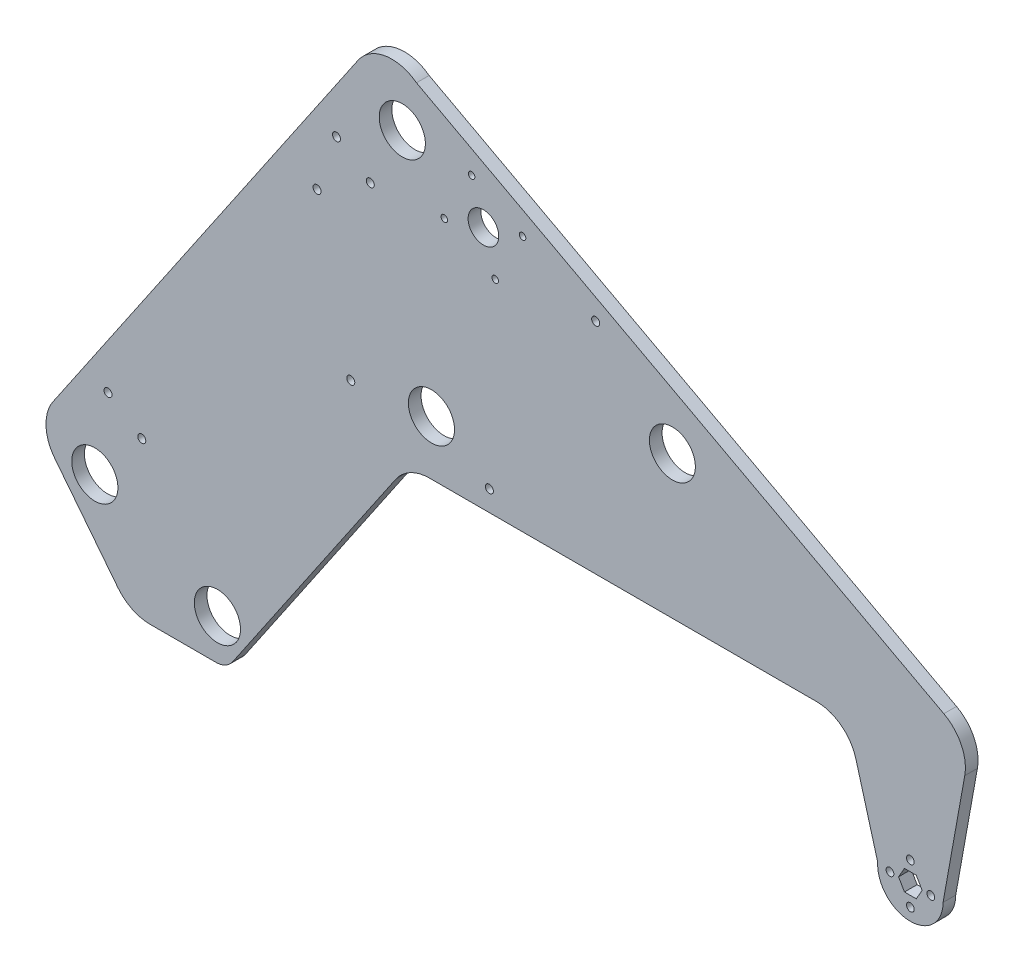
from build123d import *

# Parameters (mm, degrees)
MODEL_R             = 14.351
MODEL_R_2           = 2.413
MODEL_R_3           = 14.2875
BOSS_EXTRUDE1_DEPTH = 7.874
CUT_EXTRUDE3_REACH  = 9.874
SKETCH29_R          = 2.032
SKETCH29_R_2        = 9.525
CUT_EXTRUDE4_REACH  = 9.874
SKETCH34_R          = 2.4892
CUT_EXTRUDE5_REACH  = 9.874
SKETCH40_R          = 2.4892


with BuildPart() as part:
    # Model → Boss-Extrude1 (new body)
    with BuildSketch(Plane.XY):
        with BuildLine():
            Line((-44.522451968, 230.070582963), (-200.005250584, 313.419470721))
            ThreePointArc((-200.005250584, 313.419470721), (-219.438743814, 318.210854709), (-236.308771814, 307.439588539))
            Line((-236.308771814, 307.439588539), (-425.925316767, 28.829603592))
            ThreePointArc((-425.925316767, 28.829603592), (-430.312243104, 13.671313347), (-424.900993017, -1.152223962))
            Line((-424.900993017, -1.152223962), (-385.581467186, -51.204797614))
            ThreePointArc((-385.581467186, -51.204797614), (-376.711879358, -58.358090396), (-365.607528193, -60.913979882))
            Line((-365.607528193, -60.913979882), (-324.737451002, -60.913979882))
            ThreePointArc((-324.737451002, -60.913979882), (-318.798508014, -59.439796386), (-314.23831963, -55.359484793))
            Line((-314.23831963, -55.359484793), (-212.899365952, 93.541257838))
            ThreePointArc((-212.899365952, 93.541257838), (-203.778989185, 101.701881024), (-191.901103209, 104.650248016))
            Line((-191.901103209, 104.650248016), (48.661197018, 104.650248016))
            ThreePointArc((48.661197018, 104.650248016), (64.032332507, 99.471232012), (73.135172194, 86.046168785))
            Line((73.135172194, 86.046168785), (86.727013732, 37.098218434))
            ThreePointArc((86.727013732, 37.098218434), (106.362581421, 15.501750179), (127.326236921, 35.811553418))
            Line((127.326236921, 35.811553418), (140.807890588, 110.809453484))
            ThreePointArc((140.807890588, 110.809453484), (138.675228362, 126.361225539), (127.809114586, 137.689660276))
            Line((127.809114586, 137.689660276), (-44.522451968, 230.070582963))
        make_face()
        with Locations((-323.775189267, -35.513979882)):
            Circle(MODEL_R, mode=Mode.SUBTRACT)
        with Locations((-399.975189267, 2.586020118)):
            Circle(MODEL_R, mode=Mode.SUBTRACT)
        with Locations((107.006236921, 23.111553418)):
            Circle(MODEL_R_2, mode=Mode.SUBTRACT)
        with Locations((94.306236921, 35.811553418)):
            Circle(MODEL_R_2, mode=Mode.SUBTRACT)
        Polygon((110.67241113, 42.161553418), (114.33858534, 35.811553418), (110.67241113, 29.461553418), (103.340062712, 29.461553418), (99.673888502, 35.811553418), (103.340062712, 42.161553418), (107.006236921, 42.161553418), align=None, mode=Mode.SUBTRACT)
        with Locations((119.706236921, 35.811553418)):
            Circle(MODEL_R_2, mode=Mode.SUBTRACT)
        with Locations((107.006236921, 48.511553418)):
            Circle(MODEL_R_2, mode=Mode.SUBTRACT)
        with Locations((-190.707148919, 138.516914683)):
            Circle(MODEL_R, mode=Mode.SUBTRACT)
        with Locations((-208.832932893, 283.437784316)):
            Circle(MODEL_R, mode=Mode.SUBTRACT)
        with Locations((-40.935516122, 193.433854171)):
            Circle(MODEL_R_3, mode=Mode.SUBTRACT)
    extrude(amount=BOSS_EXTRUDE1_DEPTH)

    # Sketch29 → Cut-Extrude3 (cut, up to next)
    with BuildSketch(Plane.XY.offset(7.874), mode=Mode.PRIVATE) as cut_extrude3_sk1:
        with Locations((-182.711721066, 249.056735353)):
            Circle(SKETCH29_R)
    cut_extrude3_tool1 = extrude(cut_extrude3_sk1.sketch, amount=-CUT_EXTRUDE3_REACH, mode=Mode.PRIVATE) & part.part
    add(cut_extrude3_tool1.solids().sort_by_distance((-182.711721, 249.056735, 7.874))[0], mode=Mode.SUBTRACT)
    # Sketch29 → Cut-Extrude3 (cut, up to next)
    with BuildSketch(Plane.XY.offset(7.874), mode=Mode.PRIVATE) as cut_extrude3_sk2:
        with Locations((-134.081376724, 263.744472048)):
            Circle(SKETCH29_R)
    cut_extrude3_tool2 = extrude(cut_extrude3_sk2.sketch, amount=-CUT_EXTRUDE3_REACH, mode=Mode.PRIVATE) & part.part
    add(cut_extrude3_tool2.solids().sort_by_distance((-134.081377, 263.744472, 7.874))[0], mode=Mode.SUBTRACT)
    # Sketch29 → Cut-Extrude3 (cut, up to next)
    with BuildSketch(Plane.XY.offset(7.874), mode=Mode.PRIVATE) as cut_extrude3_sk3:
        with Locations((-165.740417242, 280.715775871)):
            Circle(SKETCH29_R)
    cut_extrude3_tool3 = extrude(cut_extrude3_sk3.sketch, amount=-CUT_EXTRUDE3_REACH, mode=Mode.PRIVATE) & part.part
    add(cut_extrude3_tool3.solids().sort_by_distance((-165.740417, 280.715776, 7.874))[0], mode=Mode.SUBTRACT)
    # Sketch29 → Cut-Extrude3 (cut, up to next)
    with BuildSketch(Plane.XY.offset(7.874), mode=Mode.PRIVATE) as cut_extrude3_sk4:
        with Locations((-151.052680548, 232.08543153)):
            Circle(SKETCH29_R)
    cut_extrude3_tool4 = extrude(cut_extrude3_sk4.sketch, amount=-CUT_EXTRUDE3_REACH, mode=Mode.PRIVATE) & part.part
    add(cut_extrude3_tool4.solids().sort_by_distance((-151.052681, 232.085432, 7.874))[0], mode=Mode.SUBTRACT)
    # Sketch29 → Cut-Extrude3 (cut, up to next)
    with BuildSketch(Plane.XY.offset(7.874), mode=Mode.PRIVATE) as cut_extrude3_sk5:
        with Locations((-158.396548895, 256.400603701)):
            Circle(SKETCH29_R_2)
    cut_extrude3_tool5 = extrude(cut_extrude3_sk5.sketch, amount=-CUT_EXTRUDE3_REACH, mode=Mode.PRIVATE) & part.part
    add(cut_extrude3_tool5.solids().sort_by_distance((-158.396549, 256.400604, 7.874))[0], mode=Mode.SUBTRACT)

    # Sketch34 → Cut-Extrude4 (cut, up to next)
    with BuildSketch(Plane.XY.offset(7.874), mode=Mode.PRIVATE) as cut_extrude4_sk1:
        with Locations((-228.733222311, 245.210842485)):
            Circle(SKETCH34_R)
    cut_extrude4_tool1 = extrude(cut_extrude4_sk1.sketch, amount=-CUT_EXTRUDE4_REACH, mode=Mode.PRIVATE) & part.part
    add(cut_extrude4_tool1.solids().sort_by_distance((-228.733222, 245.210842, 7.874))[0], mode=Mode.SUBTRACT)
    # Sketch34 → Cut-Extrude4 (cut, up to next)
    with BuildSketch(Plane.XY.offset(7.874), mode=Mode.PRIVATE) as cut_extrude4_sk2:
        with Locations((-249.731485055, 259.501852308)):
            Circle(SKETCH34_R)
    cut_extrude4_tool2 = extrude(cut_extrude4_sk2.sketch, amount=-CUT_EXTRUDE4_REACH, mode=Mode.PRIVATE) & part.part
    add(cut_extrude4_tool2.solids().sort_by_distance((-249.731485, 259.501852, 7.874))[0], mode=Mode.SUBTRACT)
    # Sketch34 → Cut-Extrude4 (cut, up to next)
    with BuildSketch(Plane.XY.offset(7.874), mode=Mode.PRIVATE) as cut_extrude4_sk3:
        with Locations((-391.784122689, 50.779120634)):
            Circle(SKETCH34_R)
    cut_extrude4_tool3 = extrude(cut_extrude4_sk3.sketch, amount=-CUT_EXTRUDE4_REACH, mode=Mode.PRIVATE) & part.part
    add(cut_extrude4_tool3.solids().sort_by_distance((-391.784123, 50.779121, 7.874))[0], mode=Mode.SUBTRACT)
    # Sketch34 → Cut-Extrude4 (cut, up to next)
    with BuildSketch(Plane.XY.offset(7.874), mode=Mode.PRIVATE) as cut_extrude4_sk4:
        with Locations((-370.785859945, 36.488110812)):
            Circle(SKETCH34_R)
    cut_extrude4_tool4 = extrude(cut_extrude4_sk4.sketch, amount=-CUT_EXTRUDE4_REACH, mode=Mode.PRIVATE) & part.part
    add(cut_extrude4_tool4.solids().sort_by_distance((-370.78586, 36.488111, 7.874))[0], mode=Mode.SUBTRACT)

    # Sketch40 → Cut-Extrude5 (cut, up to next)
    with BuildSketch(Plane(origin=(0, 0, 0), x_dir=(-1, 0, 0), z_dir=(0, 0, -1)), mode=Mode.PRIVATE) as cut_extrude5_sk1:
        with Locations((88.612396107, 240.73693678)):
            Circle(SKETCH40_R)
    cut_extrude5_tool1 = extrude(cut_extrude5_sk1.sketch, amount=-CUT_EXTRUDE5_REACH, mode=Mode.PRIVATE) & part.part
    add(cut_extrude5_tool1.solids().sort_by_distance((-88.612396, 240.736937, 0))[0], mode=Mode.SUBTRACT)
    # Sketch40 → Cut-Extrude5 (cut, up to next)
    with BuildSketch(Plane(origin=(0, 0, 0), x_dir=(-1, 0, 0), z_dir=(0, 0, -1)), mode=Mode.PRIVATE) as cut_extrude5_sk2:
        with Locations((154.68970629, 117.473322969)):
            Circle(SKETCH40_R)
    cut_extrude5_tool2 = extrude(cut_extrude5_sk2.sketch, amount=-CUT_EXTRUDE5_REACH, mode=Mode.PRIVATE) & part.part
    add(cut_extrude5_tool2.solids().sort_by_distance((-154.689706, 117.473323, 0))[0], mode=Mode.SUBTRACT)
    # Sketch40 → Cut-Extrude5 (cut, up to next)
    with BuildSketch(Plane(origin=(0, 0, 0), x_dir=(-1, 0, 0), z_dir=(0, 0, -1)), mode=Mode.PRIVATE) as cut_extrude5_sk3:
        with Locations((240.850237606, 132.8680637)):
            Circle(SKETCH40_R)
    cut_extrude5_tool3 = extrude(cut_extrude5_sk3.sketch, amount=-CUT_EXTRUDE5_REACH, mode=Mode.PRIVATE) & part.part
    add(cut_extrude5_tool3.solids().sort_by_distance((-240.850238, 132.868064, 0))[0], mode=Mode.SUBTRACT)
    # Sketch40 → Cut-Extrude5 (cut, up to next)
    with BuildSketch(Plane(origin=(0, 0, 0), x_dir=(-1, 0, 0), z_dir=(0, 0, -1)), mode=Mode.PRIVATE) as cut_extrude5_sk4:
        with Locations((261.829815531, 225.169665851)):
            Circle(SKETCH40_R)
    cut_extrude5_tool4 = extrude(cut_extrude5_sk4.sketch, amount=-CUT_EXTRUDE5_REACH, mode=Mode.PRIVATE) & part.part
    add(cut_extrude5_tool4.solids().sort_by_distance((-261.829816, 225.169666, 0))[0], mode=Mode.SUBTRACT)


solid = part.part
